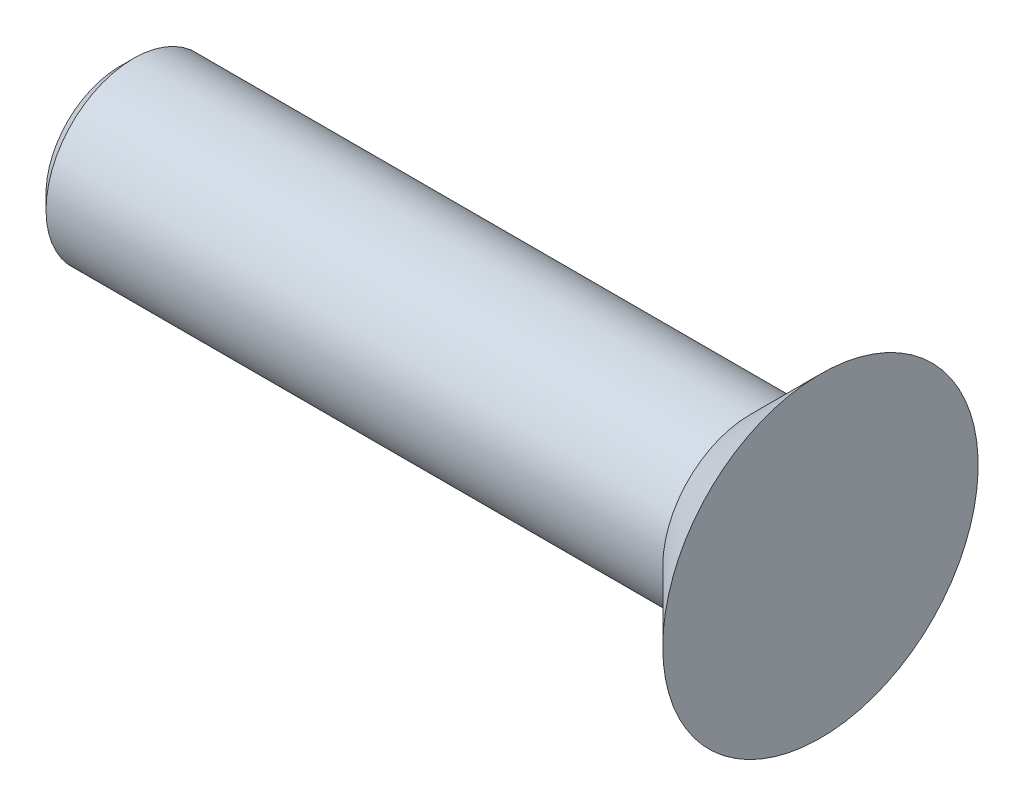
from build123d import *

# Parameters (mm, degrees)
CHANFREIN1_SIZE = 0.4


with BuildPart() as part:
    # Esquisse1 → Révolution1 (revolve)
    with BuildSketch(Plane.XY, mode=Mode.PRIVATE) as r_volution1_sk:
        Polygon((0, 0), (-20, 0), (-20, 2.5), (-2, 2.5), (0, 4.5), align=None)
    revolve(r_volution1_sk.sketch.rotate(Axis((0, 0, 0), (1, 0, 0)), 90), axis=Axis((0, 0, 0), (1, 0, 0)))  # turned: the seam where the file's is

    # Chanfrein1
    chanfrein1_edges = [part.edges().sort_by_distance(p)[0] for p in [
        (-20, 0, -2.5),
    ]]
    chamfer(chanfrein1_edges, length=CHANFREIN1_SIZE)


solid = part.part
